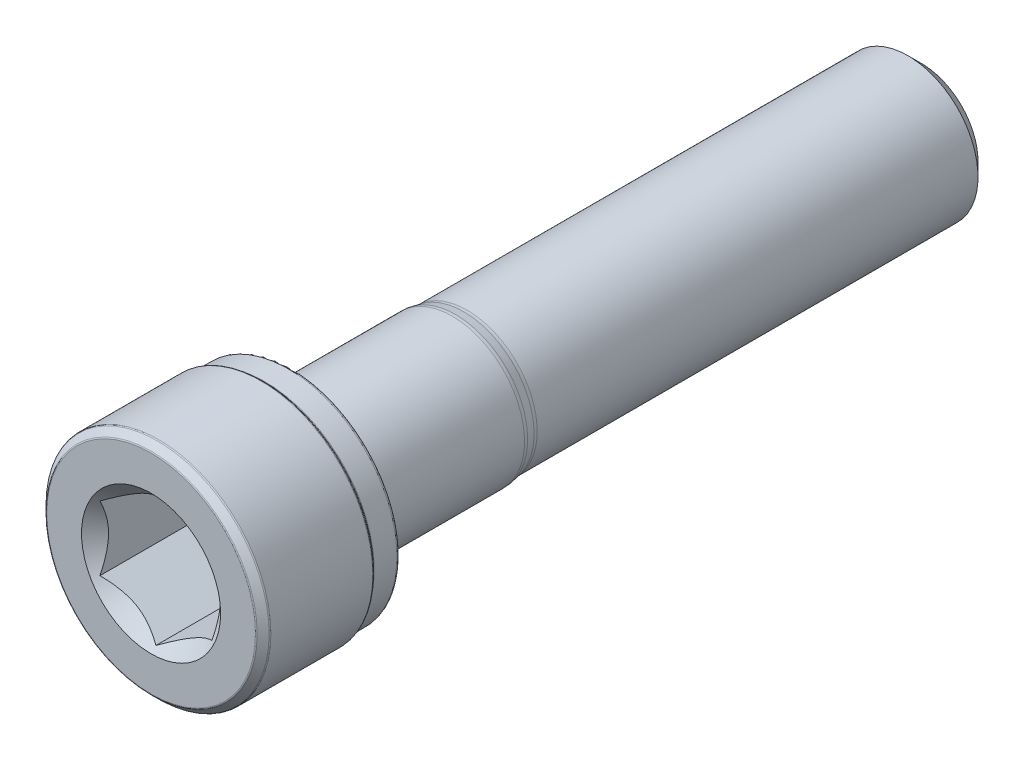
from build123d import *

# Parameters (mm, degrees)
CUT_EXTRUDE1_DEPTH = 9


with BuildPart() as part:
    # Sketch2 → Revolve1 (revolve)
    with BuildSketch(Plane(origin=(0, 0, 0), x_dir=(0, 0, -1), z_dir=(1, 0, 0)), mode=Mode.PRIVATE) as revolve1_sk:
        with BuildLine():
            Line((-27.5, 0), (-27.5, 7.448223305))
            ThreePointArc((-27.5, 7.448223305), (-27.490484942, 7.496058734), (-27.463388348, 7.536611652))
            Line((-27.463388348, 7.536611652), (-27.036611652, 7.963388348))
            ThreePointArc((-27.036611652, 7.963388348), (-26.996058734, 7.990484942), (-26.948223305, 8))
            Line((-26.948223305, 8), (-19.676776695, 8))
            ThreePointArc((-19.676776695, 8), (-19.628941266, 7.990484942), (-19.588388348, 7.963388348))
            Line((-19.588388348, 7.963388348), (-19.411611652, 7.786611652))
            ThreePointArc((-19.411611652, 7.786611652), (-19.371058734, 7.759515058), (-19.323223305, 7.75))
            Line((-19.323223305, 7.75), (-17.7, 7.75))
            ThreePointArc((-17.7, 7.75), (-17.558578644, 7.691421356), (-17.5, 7.55))
            Line((-17.5, 7.55), (-17.5, 5.662379763))
            ThreePointArc((-17.5, 5.662379763), (-17.353553391, 5.308826373), (-17, 5.162379763))
            Line((-17, 5.162379763), (-6.001952451, 5.162379763))
            ThreePointArc((-6.001952451, 5.162379763), (-5.879431025, 5.156360672), (-5.758089548, 5.138361364))
            Line((-5.758089548, 5.138361364), (-5.183248648, 5.024018399))
            ThreePointArc((-5.183248648, 5.024018399), (-5.061907171, 5.006019092), (-4.939385746, 5))
            Line((-4.939385746, 5), (26.525721421, 5))
            Line((26.525721421, 5), (27.5, 4.025721421))
            Line((27.5, 4.025721421), (27.5, 0))
            Line((27.5, 0), (-27.5, 0))
        make_face()
    revolve(revolve1_sk.sketch.rotate(Axis((0, 0, -27.5), (0, 0, 1)), 90), axis=Axis((0, 0, -27.5), (0, 0, 1)))

    # Sketch3 → Cut-Extrude1 (cut)
    with BuildSketch(Plane.XY.offset(27.5)):
        Polygon((4, -2.309401077), (4, 2.309401077), (0, 4.618802154), (-4, 2.309401077), (-4, -2.309401077), (0, -4.618802154), align=None)
    extrude(amount=-CUT_EXTRUDE1_DEPTH, mode=Mode.SUBTRACT)

    # Cut-Extrude2 cone 1 section (through the dimple's axis) → Cut-Extrude2 (revolve, cut)
    with BuildSketch(Plane(origin=(0, 0, 27.5), x_dir=(0, -1, 0), z_dir=(1, 0, 0))):
        Polygon((0, 0), (4.965212315, 0), (0, 4.965212315), align=None)
    revolve(axis=Axis((0, 0, 27.5), (0, 0, -1)), mode=Mode.SUBTRACT)


solid = part.part
